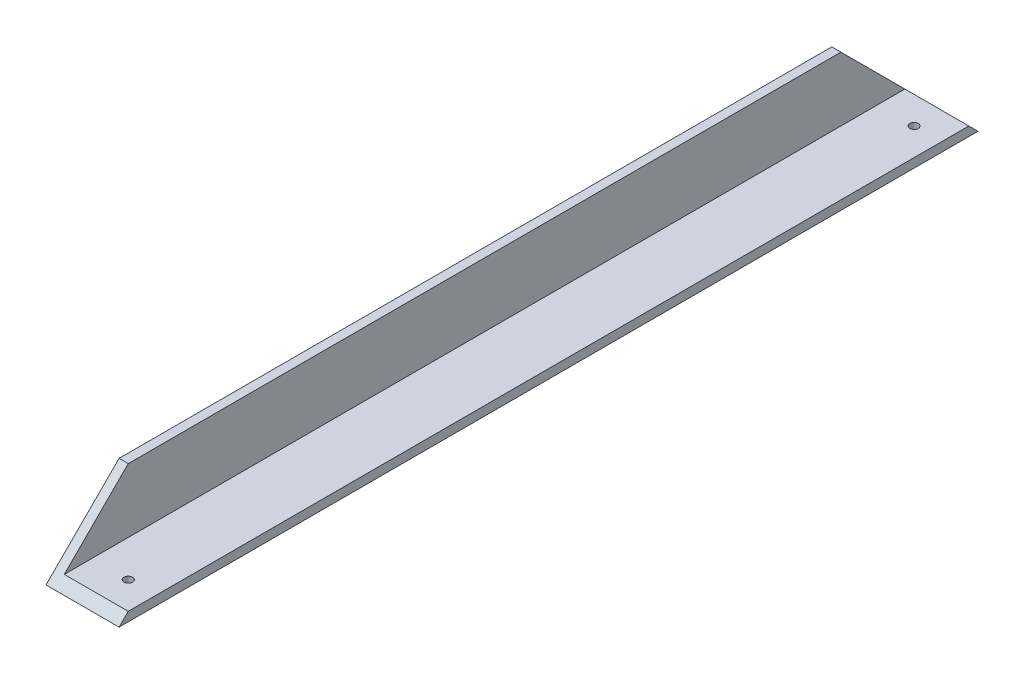
from build123d import *

# Parameters (mm, degrees)
BOSS_EXTRUDE1_DEPTH = 298.45
CUT_EXTRUDE1_DEPTH  = 711.2
SKETCH3_R           = 1.5
CUT_EXTRUDE2_DEPTH  = 711.2


with BuildPart() as part:
    # Sketch1 → Boss-Extrude1 (new body)
    with BuildSketch(Plane.XY):
        Polygon((0, 25.4), (0, 0), (25.4, 0), (25.4, 3.175), (3.175, 3.175), (3.175, 25.4), align=None)
    extrude(amount=BOSS_EXTRUDE1_DEPTH)

    # Sketch2 → Cut-Extrude1 (cut)
    with BuildSketch(Plane.ZY):
        Polygon((0, 8.542079309), (0, 0), (25.4, 25.4), (0, 25.4), align=None)
        Polygon((298.45, 25.4), (273.05, 25.4), (298.45, 0), align=None)
    extrude(amount=-CUT_EXTRUDE1_DEPTH, mode=Mode.SUBTRACT)

    # Sketch3 → Cut-Extrude2 (cut)
    with BuildSketch(Plane.XZ):
        with Locations((15.875, 285.75)):
            Circle(SKETCH3_R)
        with Locations((15.875, 12.7)):
            Circle(SKETCH3_R)
    extrude(amount=-CUT_EXTRUDE2_DEPTH, mode=Mode.SUBTRACT)


solid = part.part
